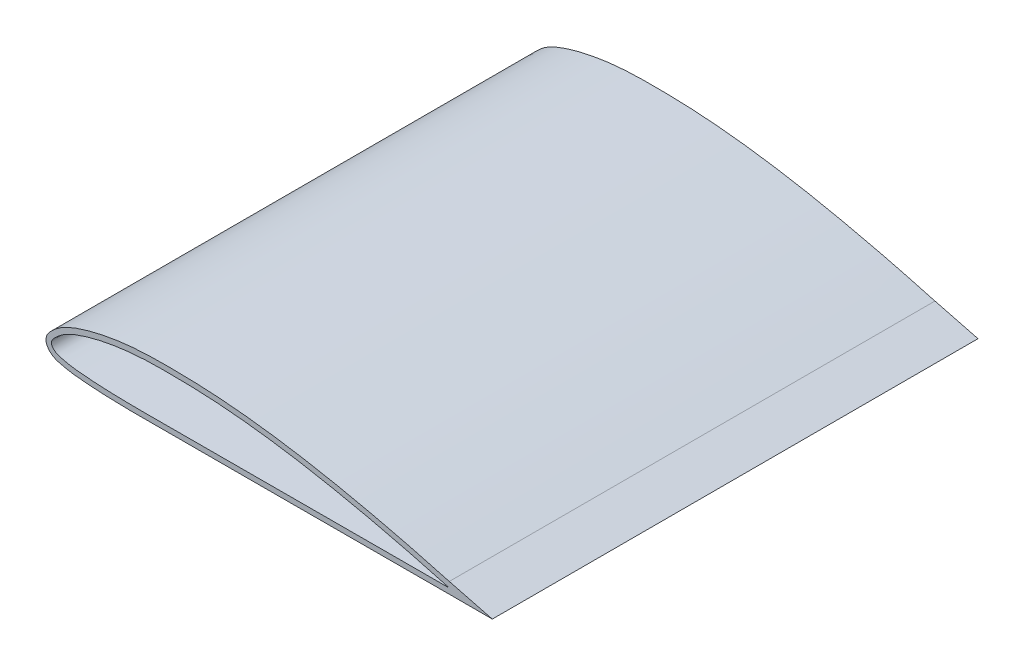
from build123d import *

# Parameters (mm, degrees)
BOSS_EXTRUDE1_DEPTH     = 600
SKETCH3_W               = 35
SKETCH3_H               = 300
CUT_EXTRUDE1_DEPTH      = 619.25770195
CUT_EXTRUDE1_DEPTH_BACK = 619.25770195
BOSS_EXTRUDE2_DEPTH     = 2
BOSS_EXTRUDE3_DEPTH     = 2
BOSS_EXTRUDE4_DEPTH     = 296
SKETCH7_W               = 40
SKETCH7_H               = 40
CUT_EXTRUDE2_DEPTH      = 619.25770195
FILLET1_R               = 5
BOSS_EXTRUDE5_REACH     = 705.269
CUT_EXTRUDE3_DEPTH      = 20


with BuildPart() as part:
    # Sketch2 → Boss-Extrude1 (new body)
    with BuildSketch(Plane.XY):
        with BuildLine():
            Line((1.535215778, 2.104151955), (17.492312071, -2.000595376))
            Line((17.492312071, -2.000595376), (1.003807611, -2.000595376))
            add(Edge.make_bspline(
                [(1.535215778, 2.104151955), (-1.489505662, 2.933853479), (-7.537446753, 4.587294769), (-19.712957708, 7.6937182), (-35.016454487, 11.222937879), (-53.530845898, 14.827338822), (-69.12546009, 17.049566382), (-81.669646013, 18.277649651), (-91.132523886, 18.843085355), (-100.578503662, 19.032147683), (-108.462225557, 19.005447079), (-114.823127608, 18.671875466), (-119.600616416, 18.190219581), (-124.336161455, 17.472514733), (-128.258181422, 16.687146597), (-131.381472985, 15.913774987), (-133.704333622, 15.252810704), (-136.004938901, 14.51973015), (-138.312181755, 13.673340422), (-140.222179028, 12.824770903), (-141.728789168, 12.023225149), (-142.850562114, 11.332410028), (-143.927837205, 10.555388137), (-144.93409978, 9.693990784), (-145.667480337, 9.017060049), (-146.309832983, 8.377271541), (-146.804153318, 7.818485275), (-147.29794551, 7.135095795), (-147.673433661, 6.400721917), (-147.890465513, 5.612652503), (-147.943241407, 4.925327448), (-147.875151792, 4.283340334), (-147.683742099, 3.645438142), (-147.457347193, 3.170908063), (-147.105315384, 2.593490807), (-146.618651979, 2.013419046), (-146.004517518, 1.453076063), (-145.318542092, 0.960640819), (-144.573251274, 0.566727136), (-143.619879769, 0.187407287), (-142.50781202, -0.106908319), (-141.388343948, -0.367024517), (-140.167865234, -0.63812983), (-138.941018346, -0.85883569), (-137.306246818, -1.094956387), (-135.299204798, -1.298598743), (-132.952810944, -1.498805031), (-129.78756227, -1.737082235), (-125.84321921, -1.945988731), (-121.113091521, -2.10023992), (-116.392596798, -2.178542612), (-111.680744165, -2.207091169), (-106.975936848, -2.203805028), (-100.715063704, -2.181150618), (-92.895603229, -2.167303148), (-83.503466045, -2.154479254), (-74.11406586, -2.136122756), (-64.724293502, -2.119042278), (-52.204726192, -2.095858601), (-36.555421714, -2.068518218), (-17.775998313, -2.034191392), (-5.256103263, -2.01251305), (1.003807611, -2.000595376)],
                knots=[0, 0, 0, 0, 0.03125, 0.0625, 0.125, 0.1875, 0.25, 0.28125, 0.3125, 0.34375, 0.375, 0.390625, 0.40625, 0.421875, 0.4375, 0.4453125, 0.453125, 0.4609375, 0.46875, 0.4765625, 0.48046875, 0.484375, 0.48828125, 0.4921875, 0.49609375, 0.498046875, 0.5, 0.501953125, 0.50390625, 0.504882812, 0.505859375, 0.506835938, 0.5078125, 0.508789062, 0.509765625, 0.51171875, 0.513671875, 0.515625, 0.517578125, 0.51953125, 0.5234375, 0.52734375, 0.53125, 0.53515625, 0.5390625, 0.546875, 0.5546875, 0.5625, 0.578125, 0.59375, 0.609375, 0.625, 0.640625, 0.65625, 0.6875, 0.71875, 0.75, 0.78125, 0.8125, 0.875, 0.9375, 1, 1, 1, 1], degree=3))
        make_face()
        with BuildLine():
            Line((1.006146011, 0.175399721), (1, -0.000599))
            add(Edge.make_bspline(
                [(1.006146011, 0.175399721), (-0.935783612, 0.708084134), (-3.847481712, 1.506860008), (-8.703948562, 2.805061405), (-14.529390979, 4.31143296), (-20.365615242, 5.748971169), (-27.174061996, 7.349019512), (-33.978074235, 8.87255681), (-44.677852951, 11.073938952), (-57.330755001, 13.372822355), (-71.009548629, 15.243863732), (-80.79958979, 16.181661516), (-89.608767887, 16.757734528), (-95.488269025, 16.949372948), (-102.350261409, 17.013236255), (-107.257957682, 17.003677137), (-112.169157697, 16.8305791), (-117.092255682, 16.461150925), (-121.035843273, 15.973066987), (-125.976922577, 15.131238489), (-129.943886321, 14.259599111), (-133.888928179, 13.113562747), (-136.893257554, 12.098280948), (-139.389650859, 11.029019517), (-141.383729174, 9.919905225), (-142.798550192, 8.917902508), (-143.868342813, 7.957464114), (-144.686348929, 7.1840502), (-145.20850207, 6.61597777), (-145.597806824, 6.064290391), (-145.812968494, 5.627863129), (-145.949608602, 5.110451824), (-145.917074686, 4.68114777), (-145.781262852, 4.303708219), (-145.631722987, 4.002112103), (-145.322122744, 3.5592561), (-144.843020742, 3.084633274), (-144.08911256, 2.535035347), (-143.008167388, 2.073432454), (-141.620225791, 1.743003025), (-140.162356424, 1.39981262), (-138.700027853, 1.124107097), (-136.748239015, 0.847974469), (-134.301943532, 0.621510039), (-131.368400158, 0.379313114), (-125.498015236, 0.006362829), (-115.695266078, -0.245453373), (-101.968694839, -0.177054014), (-89.220643014, -0.164335562), (-73.530096937, -0.135235118), (-57.83955343, -0.106214113), (-42.149001448, -0.07780996), (-31.361749043, -0.05939132), (-22.535820015, -0.042588464), (-13.709885913, -0.027603429), (-5.864614813, -0.012696837), (-0.961317757, -0.004332974), (1, -0.000599)],
                knots=[0, 0, 0, 0, 0.020105055, 0.030145261, 0.050190794, 0.080180377, 0.09015591, 0.120020101, 0.149793491, 0.199219015, 0.248395636, 0.287604023, 0.297393127, 0.336534715, 0.346322474, 0.365907652, 0.385530879, 0.395375762, 0.415192461, 0.425184025, 0.445412191, 0.455710779, 0.466190959, 0.477054504, 0.482786727, 0.488945835, 0.494316033, 0.497126416, 0.500187368, 0.502000869, 0.503849971, 0.505020137, 0.507317905, 0.507986558, 0.509023586, 0.510668219, 0.513358348, 0.515715812, 0.519949385, 0.524973188, 0.5299544, 0.534903202, 0.539824123, 0.549630394, 0.559425369, 0.569214167, 0.608355933, 0.657307127, 0.70626328, 0.735636871, 0.813966735, 0.862922864, 0.892296527, 0.921670208, 0.951043871, 0.980417552, 1, 1, 1, 1], degree=3))
        make_face(mode=Mode.SUBTRACT)
    extrude(amount=BOSS_EXTRUDE1_DEPTH)

    # Sketch3 → Cut-Extrude1 (cut, two sides)
    with BuildSketch(Plane(origin=(0, 0, 0), x_dir=(1, 0, 0), z_dir=(0, 1, 0))) as cut_extrude1_sk:
        with Locations((-0.007687929, -400)):
            Rectangle(SKETCH3_W, SKETCH3_H)
    extrude(amount=CUT_EXTRUDE1_DEPTH, mode=Mode.SUBTRACT)
    extrude(cut_extrude1_sk.sketch, amount=-CUT_EXTRUDE1_DEPTH_BACK, mode=Mode.SUBTRACT)

    # Sketch4 → Boss-Extrude2 (add)
    with BuildSketch(Plane.XY.offset(250)):
        with BuildLine():
            add(Edge.make_bspline(
                [(-19.507687929, 5.529173109), (-18.840739539, 5.367007358), (-18.174074767, 5.203673471), (-17.507687929, 5.039210768)],
                knots=[-0.00685304, -0.00685304, -0.00685304, -0.00685304, 0, 0, 0, 0], degree=3))
            Line((-19.507687929, 5.529173109), (-19.507687929, -0.037521046))
            add(Edge.make_bspline(
                [(-17.507687929, -0.034020629), (-18.174354596, -0.035187113), (-18.841021267, -0.03635159), (-19.507687929, -0.037521046)],
                knots=[1, 1, 1, 1, 1.00665622, 1.00665622, 1.00665622, 1.00665622], degree=3))
            add(Edge.make_bspline(
                [(1, -0.000599), (-0.961317757, -0.004332974), (-5.864614813, -0.012696837), (-12.033843076, -0.024418824), (-16.24175466, -0.031805591), (-17.507687929, -0.034020629)],
                knots=[0.938404376, 0.938404376, 0.938404376, 0.938404376, 0.957986824, 0.987360505, 1, 1, 1, 1], degree=3))
            Line((1, -0.000599), (1.006146011, 0.175399721))
            add(Edge.make_bspline(
                [(-17.507687929, 5.039210768), (-16.193194667, 4.714796926), (-12.932166912, 3.898414905), (-8.703948562, 2.805061405), (-3.847481712, 1.506860008), (-0.935783612, 0.708084134), (1.006146011, 0.175399721)],
                knots=[0, 0, 0, 0, 0.013518086, 0.03356362, 0.043603826, 0.063708881, 0.063708881, 0.063708881, 0.063708881], degree=3))
        make_face()
        with BuildLine():
            add(Edge.make_bspline(
                [(1.535215778, 2.104151955), (-1.489505662, 2.933853479), (-7.537446753, 4.587294769), (-13.902312123, 6.211207473), (-17.229974375, 7.030436817), (-17.507687929, 7.098598456)],
                knots=[0, 0, 0, 0, 0.03125, 0.0625, 0.065344951, 0.065344951, 0.065344951, 0.065344951], degree=3))
            Line((-17.507687929, 7.098598456), (-17.507687929, 5.039210769))
            add(Edge.make_bspline(
                [(-17.507687929, 5.039210768), (-16.193194667, 4.714796926), (-12.932166912, 3.898414905), (-8.703948562, 2.805061405), (-3.847481712, 1.506860008), (-0.935783612, 0.708084134), (1.006146011, 0.175399721)],
                knots=[0, 0, 0, 0, 0.013518086, 0.03356362, 0.043603826, 0.063708881, 0.063708881, 0.063708881, 0.063708881], degree=3))
            add(Edge.make_bspline(
                [(1.006146011, 0.175399721), (1.218526671, 0.117142271), (1.430907381, 0.058885425), (1.643291149, 0.000640339)],
                knots=[0.063708881, 0.063708881, 0.063708881, 0.063708881, 0.065907686, 0.065907686, 0.065907686, 0.065907686], degree=3))
            add(Edge.make_bspline(
                [(9.170732977, 0.018651944), (6.661588405, 0.011160584), (4.152440444, 0.005534208), (1.643291149, 0.000640339)],
                knots=[0.91121125, 0.91121125, 0.91121125, 0.91121125, 0.936263432, 0.936263432, 0.936263432, 0.936263432], degree=3))
            add(Edge.make_bspline(
                [(9.170732977, 0.018651945), (6.620791505, 0.707183501), (4.077738359, 1.406720836), (1.535215778, 2.104151955)],
                knots=[-0.026268148, -0.026268148, -0.026268148, -0.026268148, 0, 0, 0, 0], degree=3))
        make_face()
        with BuildLine():
            Line((9.637044934, 0.020065917), (1.535215778, 2.104151955))
            add(Edge.make_bspline(
                [(9.170732977, 0.018651945), (6.620791505, 0.707183501), (4.077738359, 1.406720836), (1.535215778, 2.104151955)],
                knots=[-0.026268148, -0.026268148, -0.026268148, -0.026268148, 0, 0, 0, 0], degree=3))
            add(Edge.make_bspline(
                [(9.637044934, 0.020065917), (9.481607628, 0.019587256), (9.326170309, 0.019116022), (9.170732977, 0.018651944)],
                knots=[0.909659309, 0.909659309, 0.909659309, 0.909659309, 0.91121125, 0.91121125, 0.91121125, 0.91121125], degree=3))
        make_face()
        with BuildLine():
            add(Edge.make_bspline(
                [(1, -0.000599), (-0.961317757, -0.004332974), (-5.864614813, -0.012696837), (-12.033843076, -0.024418824), (-16.24175466, -0.031805591), (-17.507687929, -0.034020629)],
                knots=[0.938404376, 0.938404376, 0.938404376, 0.938404376, 0.957986824, 0.987360505, 1, 1, 1, 1], degree=3))
            Line((-17.507687929, -0.034020629), (-17.507687929, -2.034015736))
            add(Edge.make_bspline(
                [(-17.507687929, -2.034015736), (-11.337221813, -2.023042356), (-5.166689295, -2.012342822), (1.003807611, -2.000595376)],
                knots=[0.938392724, 0.938392724, 0.938392724, 0.938392724, 1, 1, 1, 1], degree=3))
            add(Edge.make_bspline(
                [(1.003807611, -2.000595376), (3.658262279, -1.995541801), (6.312710356, -1.990294301), (8.967143722, -1.98474765)],
                knots=[1, 1, 1, 1, 1.026502521, 1.026502521, 1.026502521, 1.026502521], degree=3))
            add(Edge.make_bspline(
                [(1.643291149, 0.000640339), (4.082652652, -0.668341207), (6.522417522, -1.335771436), (8.967143722, -1.984747651)],
                knots=[0.065907686, 0.065907686, 0.065907686, 0.065907686, 0.09116235, 0.09116235, 0.09116235, 0.09116235], degree=3))
            add(Edge.make_bspline(
                [(1.643291149, 0.000640339), (1.428860775, 0.000222112), (1.214430392, -0.000190766), (1, -0.000599)],
                knots=[0.936263432, 0.936263432, 0.936263432, 0.936263432, 0.938404376, 0.938404376, 0.938404376, 0.938404376], degree=3))
        make_face()
        with BuildLine():
            add(Edge.make_bspline(
                [(1.006146011, 0.175399721), (1.218526671, 0.117142271), (1.430907381, 0.058885425), (1.643291149, 0.000640339)],
                knots=[0.063708881, 0.063708881, 0.063708881, 0.063708881, 0.065907686, 0.065907686, 0.065907686, 0.065907686], degree=3))
            Line((1.006146011, 0.175399721), (1, -0.000599))
            add(Edge.make_bspline(
                [(1.643291149, 0.000640339), (1.428860775, 0.000222112), (1.214430392, -0.000190766), (1, -0.000599)],
                knots=[0.936263432, 0.936263432, 0.936263432, 0.936263432, 0.938404376, 0.938404376, 0.938404376, 0.938404376], degree=3))
        make_face()
        with BuildLine():
            Line((17.358189622, -1.966094188), (9.637044934, 0.020065917))
            add(Edge.make_bspline(
                [(9.637044934, 0.020065917), (9.481607628, 0.019587256), (9.326170309, 0.019116022), (9.170732977, 0.018651944)],
                knots=[0.909659309, 0.909659309, 0.909659309, 0.909659309, 0.91121125, 0.91121125, 0.91121125, 0.91121125], degree=3))
            add(Edge.make_bspline(
                [(16.717058799, -1.96760649), (14.190932933, -1.324461466), (11.677504422, -0.658222902), (9.170732977, 0.018651945)],
                knots=[-0.052091581, -0.052091581, -0.052091581, -0.052091581, -0.026268148, -0.026268148, -0.026268148, -0.026268148], degree=3))
            add(Edge.make_bspline(
                [(16.7170588, -1.967606477), (16.930769222, -1.967105002), (17.144479497, -1.966600924), (17.358189622, -1.966094188)],
                knots=[1.052295042, 1.052295042, 1.052295042, 1.052295042, 1.054428809, 1.054428809, 1.054428809, 1.054428809], degree=3))
        make_face()
        with BuildLine():
            add(Edge.make_bspline(
                [(16.717058799, -1.96760649), (14.190932933, -1.324461466), (11.677504422, -0.658222902), (9.170732977, 0.018651945)],
                knots=[-0.052091581, -0.052091581, -0.052091581, -0.052091581, -0.026268148, -0.026268148, -0.026268148, -0.026268148], degree=3))
            add(Edge.make_bspline(
                [(9.170732977, 0.018651944), (6.661588405, 0.011160584), (4.152440444, 0.005534208), (1.643291149, 0.000640339)],
                knots=[0.91121125, 0.91121125, 0.91121125, 0.91121125, 0.936263432, 0.936263432, 0.936263432, 0.936263432], degree=3))
            add(Edge.make_bspline(
                [(1.643291149, 0.000640339), (4.082652652, -0.668341207), (6.522417522, -1.335771436), (8.967143722, -1.984747651)],
                knots=[0.065907686, 0.065907686, 0.065907686, 0.065907686, 0.09116235, 0.09116235, 0.09116235, 0.09116235], degree=3))
            add(Edge.make_bspline(
                [(8.967143722, -1.98474765), (11.550465178, -1.979349593), (14.133772699, -1.9736682), (16.7170588, -1.967606477)],
                knots=[1.026502521, 1.026502521, 1.026502521, 1.026502521, 1.052295042, 1.052295042, 1.052295042, 1.052295042], degree=3))
        make_face()
    extrude(amount=BOSS_EXTRUDE2_DEPTH)

    # Sketch5 → Boss-Extrude3 (add)
    with BuildSketch(Plane(origin=(0, 0, 550), x_dir=(-1, 0, 0), z_dir=(0, 0, -1))):
        with BuildLine():
            Line((17.507687929, 5.039210768), (17.507687929, 7.098598457))
            add(Edge.make_bspline(
                [(17.507687929, 7.098598457), (17.229974375, 7.030436817), (13.902312123, 6.211207473), (7.537446753, 4.587294769), (1.489505662, 2.933853479), (-1.535215778, 2.104151955)],
                knots=[0, 0, 0, 0, 0.002844951, 0.034094951, 0.065344951, 0.065344951, 0.065344951, 0.065344951], degree=3))
            Line((-1.535215778, 2.104151955), (-17.358189622, -1.966094188))
            add(Edge.make_bspline(
                [(-17.358189622, -1.966094188), (-11.906803647, -1.979020167), (-6.455319527, -1.990216739), (-1.003807611, -2.000595376)],
                knots=[1, 1, 1, 1, 1.054428809, 1.054428809, 1.054428809, 1.054428809], degree=3))
            add(Edge.make_bspline(
                [(-1.003807611, -2.000595376), (5.166689295, -2.012342822), (11.337221813, -2.023042356), (17.507687929, -2.034015736)],
                knots=[0.938392724, 0.938392724, 0.938392724, 0.938392724, 1, 1, 1, 1], degree=3))
            Line((17.507687929, -2.034015736), (17.507687929, -0.034020629))
            Line((17.507687929, -0.034020629), (19.507687929, -0.037521046))
            Line((19.507687929, -0.037521046), (19.507687929, 5.529173111))
            ThreePointArc((19.507687929, 5.529173111), (18.507476937, 5.285053195), (17.507687929, 5.039210768))
        make_face()
    extrude(amount=BOSS_EXTRUDE3_DEPTH)

    # Sketch6 → Boss-Extrude4 (add)
    with BuildSketch(Plane(origin=(0, 0, 548), x_dir=(-1, 0, 0), z_dir=(0, 0, -1))):
        with BuildLine():
            Line((17.507687929, 5.039210768), (17.507687929, -0.034020629))
            Line((17.507687929, -0.034020629), (19.507687929, -0.037521046))
            Line((19.507687929, -0.037521046), (19.507687929, 5.529173111))
            ThreePointArc((19.507687929, 5.529173111), (18.507476937, 5.285053196), (17.507687929, 5.039210768))
        make_face()
    extrude(amount=BOSS_EXTRUDE4_DEPTH)

    # Sketch7 → Cut-Extrude2 (cut, through all)
    with BuildSketch(Plane(origin=(0, 0, 0), x_dir=(1, 0, 0), z_dir=(0, 1, 0))):
        with Locations((-82.92334015, -408)):
            Rectangle(SKETCH7_W, SKETCH7_H)
    extrude(amount=-CUT_EXTRUDE2_DEPTH, mode=Mode.SUBTRACT)

    # Fillet1
    fillet1_edges = [part.edges().sort_by_distance(p)[0] for p in [
        (-62.92334015, -1.115676739, 428),
        (-62.92334015, -1.115676739, 388),
        (-102.92334015, -1.18976564, 388),
        (-102.92334015, -1.18976564, 428),
    ]]
    fillet(fillet1_edges, radius=FILLET1_R)

    # Sketch8 → Boss-Extrude5 (add, up to next)
    with BuildSketch(Plane(origin=(-284.507687929, 10.368065871, -35), x_dir=(0, 0, 1), z_dir=(0, 1, 0)), mode=Mode.PRIVATE) as boss_extrude5_sk1:
        with BuildLine():
            Line((428, 181.584347778), (458, 181.584347778))
            ThreePointArc((458, 181.584347778), (461.535533906, 183.048813872), (463, 186.584347778))
            Line((463, 186.584347778), (463, 216.584347778))
            ThreePointArc((463, 216.584347778), (461.535533906, 220.119881684), (458, 221.584347778))
            Line((458, 221.584347778), (428, 221.584347778))
            ThreePointArc((428, 221.584347778), (424.464466094, 220.119881684), (423, 216.584347778))
            Line((423, 216.584347778), (423, 186.584347778))
            ThreePointArc((423, 186.584347778), (424.464466094, 183.048813872), (428, 181.584347778))
        make_face()
    boss_extrude5_tool1 = extrude(boss_extrude5_sk1.sketch, amount=BOSS_EXTRUDE5_REACH, mode=Mode.PRIVATE) - part.part
    add(boss_extrude5_tool1.solids().sort_by_distance((-82.92334, 10.368066, 408))[0])

    # Split1
    split(bisect_by=Plane(origin=(0, 0, 200), x_dir=(-1, 0, 0), z_dir=(0, 0, -1)), keep=Keep.TOP)

    # Sketch9 → Cut-Extrude3 (cut)
    with BuildSketch(Plane(origin=(0, 0, 0), x_dir=(-1, 0, 0), z_dir=(0, 0, -1))):
        with BuildLine():
            Line((-1.535215778, 2.104151955), (-17.492312071, -2.000595376))
            Line((-17.492312071, -2.000595376), (-1.003807611, -2.000595376))
            add(Edge.make_bspline(
                [(-1.003807611, -2.000595376), (5.256103263, -2.01251305), (17.775998313, -2.034191392), (36.555421714, -2.068518218), (52.204726192, -2.095858601), (64.724293502, -2.119042278), (74.11406586, -2.136122756), (83.503466045, -2.154479254), (92.895603229, -2.167303148), (100.715063704, -2.181150618), (106.975936848, -2.203805028), (111.680744165, -2.207091169), (116.392596798, -2.178542612), (121.113091521, -2.10023992), (125.84321921, -1.945988731), (129.78756227, -1.737082235), (132.952810944, -1.498805031), (135.299204798, -1.298598743), (137.306246818, -1.094956387), (138.941018346, -0.85883569), (140.167865234, -0.63812983), (141.388343948, -0.367024517), (142.50781202, -0.106908319), (143.619879769, 0.187407287), (144.573251274, 0.566727136), (145.318542092, 0.960640819), (146.004517518, 1.453076063), (146.618651979, 2.013419046), (147.105315384, 2.593490807), (147.457347193, 3.170908063), (147.683742099, 3.645438142), (147.875151792, 4.283340334), (147.943241407, 4.925327448), (147.890465513, 5.612652503), (147.673433661, 6.400721917), (147.29794551, 7.135095795), (146.804153318, 7.818485275), (146.309832983, 8.377271541), (145.667480337, 9.017060049), (144.93409978, 9.693990784), (143.927837205, 10.555388137), (142.850562114, 11.332410028), (141.728789168, 12.023225149), (140.222179028, 12.824770903), (138.312181755, 13.673340422), (136.004938901, 14.51973015), (133.704333622, 15.252810704), (131.381472985, 15.913774987), (128.258181422, 16.687146597), (124.336161455, 17.472514733), (119.600616416, 18.190219581), (114.823127608, 18.671875466), (108.462225557, 19.005447079), (100.578503662, 19.032147683), (91.132523886, 18.843085355), (81.669646013, 18.277649651), (69.12546009, 17.049566382), (53.530845898, 14.827338822), (35.016454487, 11.222937879), (19.712957708, 7.6937182), (7.537446753, 4.587294769), (1.489505662, 2.933853479), (-1.535215778, 2.104151955)],
                knots=[0, 0, 0, 0, 0.0625, 0.125, 0.1875, 0.21875, 0.25, 0.28125, 0.3125, 0.34375, 0.359375, 0.375, 0.390625, 0.40625, 0.421875, 0.4375, 0.4453125, 0.453125, 0.4609375, 0.46484375, 0.46875, 0.47265625, 0.4765625, 0.48046875, 0.482421875, 0.484375, 0.486328125, 0.48828125, 0.490234375, 0.491210938, 0.4921875, 0.493164062, 0.494140625, 0.495117188, 0.49609375, 0.498046875, 0.5, 0.501953125, 0.50390625, 0.5078125, 0.51171875, 0.515625, 0.51953125, 0.5234375, 0.53125, 0.5390625, 0.546875, 0.5546875, 0.5625, 0.578125, 0.59375, 0.609375, 0.625, 0.65625, 0.6875, 0.71875, 0.75, 0.8125, 0.875, 0.9375, 0.96875, 1, 1, 1, 1], degree=3))
        make_face()
    extrude(amount=-CUT_EXTRUDE3_DEPTH, mode=Mode.SUBTRACT)


solid = part.part
